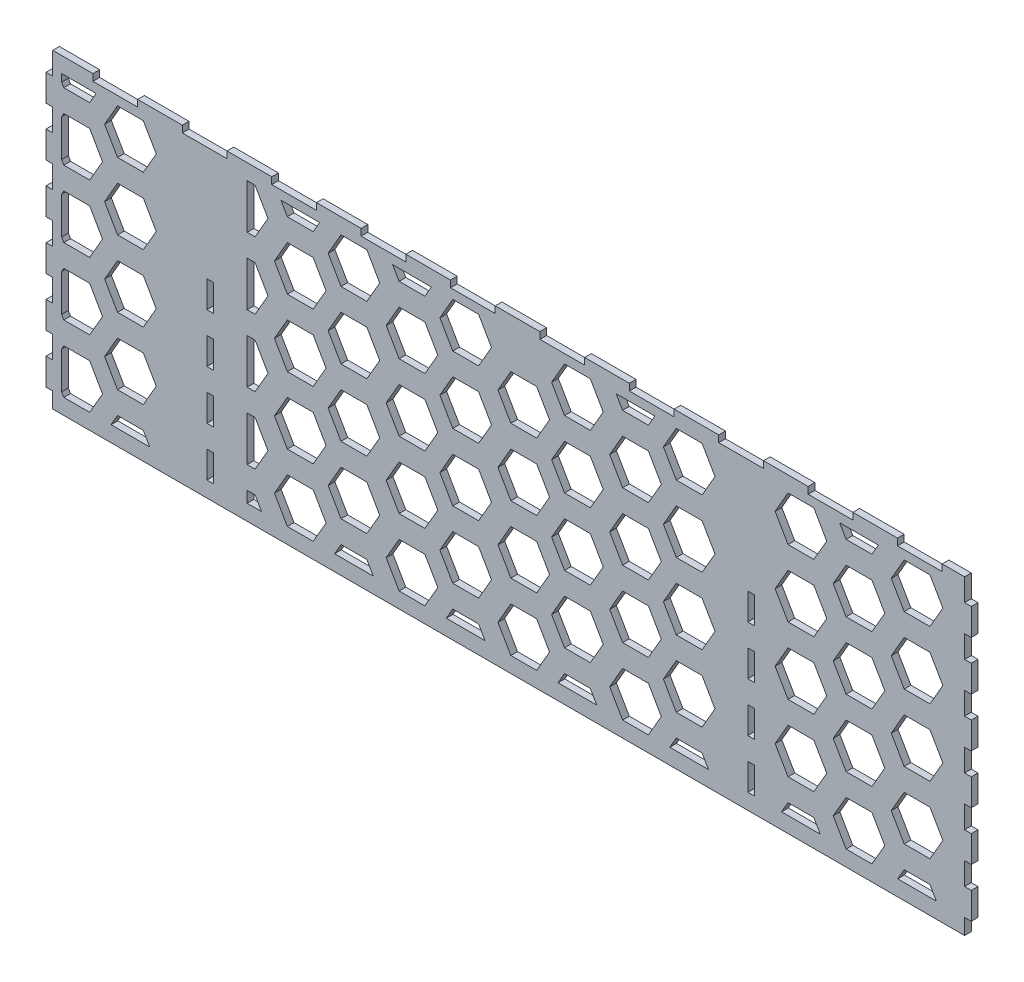
from build123d import *

# Parameters (mm, degrees)
SKETCH1_W           = 414
SKETCH1_H           = 139
SKETCH1_W_2         = 3
SKETCH1_H_2         = 12
BOSS_EXTRUDE1_DEPTH = 3
SKETCH3_W           = 20
SKETCH3_H           = 3
CUT_EXTRUDE2_DEPTH  = 3
SKETCH4_W           = 3
SKETCH4_H           = 12
CUT_EXTRUDE3_DEPTH  = 3


with BuildPart() as part:
    # Sketch1 → Boss-Extrude1 (new body)
    with BuildSketch(Plane.XY.offset(152)):
        Rectangle(SKETCH1_W, SKETCH1_H)
        with Locations((108.5, 9.5)):
            Rectangle(SKETCH1_W_2, SKETCH1_H_2, mode=Mode.SUBTRACT)
        with Locations((108.5, -12.5)):
            Rectangle(SKETCH1_W_2, SKETCH1_H_2, mode=Mode.SUBTRACT)
        with Locations((108.5, -56.5)):
            Rectangle(SKETCH1_W_2, SKETCH1_H_2, mode=Mode.SUBTRACT)
        with Locations((108.5, -34.5)):
            Rectangle(SKETCH1_W_2, SKETCH1_H_2, mode=Mode.SUBTRACT)
        with Locations((-133.5, -56.5)):
            Rectangle(SKETCH1_W_2, SKETCH1_H_2, mode=Mode.SUBTRACT)
        with Locations((-133.5, -34.5)):
            Rectangle(SKETCH1_W_2, SKETCH1_H_2, mode=Mode.SUBTRACT)
        with Locations((-133.5, -12.5)):
            Rectangle(SKETCH1_W_2, SKETCH1_H_2, mode=Mode.SUBTRACT)
        with Locations((-133.5, 9.5)):
            Rectangle(SKETCH1_W_2, SKETCH1_H_2, mode=Mode.SUBTRACT)
        Polygon((119.226497308, 52.5), (125, 42.5), (136.547005384, 42.5), (142.320508076, 52.5), (136.547005384, 62.5), (125, 62.5), align=None, mode=Mode.SUBTRACT)
        Polygon((171.188021535, 52.5), (176.961524227, 42.5), (188.508529611, 42.5), (194.282032303, 52.5), (188.508529611, 62.5), (176.961524227, 62.5), align=None, mode=Mode.SUBTRACT)
        Polygon((150.980762113, 47.5), (145.207259422, 37.5), (150.980762113, 27.5), (162.527767497, 27.5), (168.301270189, 37.5), (162.527767497, 47.5), align=None, mode=Mode.SUBTRACT)
        Polygon((171.188021535, 22.5), (176.961524227, 12.5), (188.508529611, 12.5), (194.282032303, 22.5), (188.508529611, 32.5), (176.961524227, 32.5), align=None, mode=Mode.SUBTRACT)
        Polygon((150.980762113, 17.5), (145.207259422, 7.5), (150.980762113, -2.5), (162.527767497, -2.5), (168.301270189, 7.5), (162.527767497, 17.5), align=None, mode=Mode.SUBTRACT)
        Polygon((119.226497308, 22.5), (125, 12.5), (136.547005384, 12.5), (142.320508076, 22.5), (136.547005384, 32.5), (125, 32.5), align=None, mode=Mode.SUBTRACT)
        Polygon((171.188021535, -7.5), (176.961524227, -17.5), (188.508529611, -17.5), (194.282032303, -7.5), (188.508529611, 2.5), (176.961524227, 2.5), align=None, mode=Mode.SUBTRACT)
        Polygon((150.980762113, -12.5), (145.207259422, -22.5), (150.980762113, -32.5), (162.527767497, -32.5), (168.301270189, -22.5), (162.527767497, -12.5), align=None, mode=Mode.SUBTRACT)
        Polygon((119.226497308, -7.5), (125, -17.5), (136.547005384, -17.5), (142.320508076, -7.5), (136.547005384, 2.5), (125, 2.5), align=None, mode=Mode.SUBTRACT)
        Polygon((171.188021535, -37.5), (176.961524227, -47.5), (188.508529611, -47.5), (194.282032303, -37.5), (188.508529611, -27.5), (176.961524227, -27.5), align=None, mode=Mode.SUBTRACT)
        Polygon((150.980762113, -42.5), (145.207259422, -52.5), (150.980762113, -62.5), (162.527767497, -62.5), (168.301270189, -52.5), (162.527767497, -42.5), align=None, mode=Mode.SUBTRACT)
        Polygon((119.226497308, -37.5), (125, -47.5), (136.547005384, -47.5), (142.320508076, -37.5), (136.547005384, -27.5), (125, -27.5), align=None, mode=Mode.SUBTRACT)
        Polygon((191.395280957, -62.5), (188.508529611, -57.5), (176.961524227, -57.5), (174.074772881, -62.5), align=None, mode=Mode.SUBTRACT)
        Polygon((139.43375673, -62.5), (136.547005384, -57.5), (125, -57.5), (122.113248654, -62.5), align=None, mode=Mode.SUBTRACT)
        Polygon((148.094010768, 62.5), (150.980762113, 57.5), (162.527767497, 57.5), (165.414518843, 62.5), align=None, mode=Mode.SUBTRACT)
        Polygon((89.43375673, -62.5), (86.547005384, -57.5), (75, -57.5), (72.113248654, -62.5), align=None, mode=Mode.SUBTRACT)
        Polygon((69.226497308, -37.5), (75, -47.5), (86.547005384, -47.5), (92.320508076, -37.5), (86.547005384, -27.5), (75, -27.5), align=None, mode=Mode.SUBTRACT)
        Polygon((69.226497308, -7.5), (75, -17.5), (86.547005384, -17.5), (92.320508076, -7.5), (86.547005384, 2.5), (75, 2.5), align=None, mode=Mode.SUBTRACT)
        Polygon((69.226497308, 22.5), (75, 12.5), (86.547005384, 12.5), (92.320508076, 22.5), (86.547005384, 32.5), (75, 32.5), align=None, mode=Mode.SUBTRACT)
        Polygon((69.226497308, 52.5), (75, 42.5), (86.547005384, 42.5), (92.320508076, 52.5), (86.547005384, 62.5), (75, 62.5), align=None, mode=Mode.SUBTRACT)
        Polygon((39.43375673, -62.5), (36.547005384, -57.5), (25, -57.5), (22.113248654, -62.5), align=None, mode=Mode.SUBTRACT)
        Polygon((50.980762114, -42.5), (45.207259422, -52.5), (50.980762114, -62.5), (62.527767497, -62.5), (68.301270189, -52.5), (62.527767497, -42.5), align=None, mode=Mode.SUBTRACT)
        Polygon((19.226497308, -37.5), (25, -47.5), (36.547005384, -47.5), (42.320508076, -37.5), (36.547005384, -27.5), (25, -27.5), align=None, mode=Mode.SUBTRACT)
        Polygon((50.980762114, -12.5), (45.207259422, -22.5), (50.980762114, -32.5), (62.527767497, -32.5), (68.301270189, -22.5), (62.527767497, -12.5), align=None, mode=Mode.SUBTRACT)
        Polygon((19.226497308, -7.5), (25, -17.5), (36.547005384, -17.5), (42.320508076, -7.5), (36.547005384, 2.5), (25, 2.5), align=None, mode=Mode.SUBTRACT)
        Polygon((50.980762114, 17.5), (45.207259422, 7.5), (50.980762114, -2.5), (62.527767497, -2.5), (68.301270189, 7.5), (62.527767497, 17.5), align=None, mode=Mode.SUBTRACT)
        Polygon((19.226497308, 22.5), (25, 12.5), (36.547005384, 12.5), (42.320508076, 22.5), (36.547005384, 32.5), (25, 32.5), align=None, mode=Mode.SUBTRACT)
        Polygon((50.980762114, 47.5), (45.207259422, 37.5), (50.980762114, 27.5), (62.527767497, 27.5), (68.301270189, 37.5), (62.527767497, 47.5), align=None, mode=Mode.SUBTRACT)
        Polygon((19.226497308, 52.5), (25, 42.5), (36.547005384, 42.5), (42.320508076, 52.5), (36.547005384, 62.5), (25, 62.5), align=None, mode=Mode.SUBTRACT)
        Polygon((48.094010768, 62.5), (50.980762114, 57.5), (62.527767497, 57.5), (65.414518843, 62.5), align=None, mode=Mode.SUBTRACT)
        Polygon((-10.56624327, -62.5), (-13.452994616, -57.5), (-25, -57.5), (-27.886751346, -62.5), align=None, mode=Mode.SUBTRACT)
        Polygon((0.980762114, -42.5), (-4.792740578, -52.5), (0.980762114, -62.5), (12.527767497, -62.5), (18.301270189, -52.5), (12.527767497, -42.5), align=None, mode=Mode.SUBTRACT)
        Polygon((-30.773502692, -37.5), (-25, -47.5), (-13.452994616, -47.5), (-7.679491924, -37.5), (-13.452994616, -27.5), (-25, -27.5), align=None, mode=Mode.SUBTRACT)
        Polygon((0.980762114, -12.5), (-4.792740578, -22.5), (0.980762114, -32.5), (12.527767497, -32.5), (18.301270189, -22.5), (12.527767497, -12.5), align=None, mode=Mode.SUBTRACT)
        Polygon((-30.773502692, -7.5), (-25, -17.5), (-13.452994616, -17.5), (-7.679491924, -7.5), (-13.452994616, 2.5), (-25, 2.5), align=None, mode=Mode.SUBTRACT)
        Polygon((0.980762114, 17.5), (-4.792740578, 7.5), (0.980762114, -2.5), (12.527767497, -2.5), (18.301270189, 7.5), (12.527767497, 17.5), align=None, mode=Mode.SUBTRACT)
        Polygon((-30.773502692, 22.5), (-25, 12.5), (-13.452994616, 12.5), (-7.679491924, 22.5), (-13.452994616, 32.5), (-25, 32.5), align=None, mode=Mode.SUBTRACT)
        Polygon((0.980762114, 47.5), (-4.792740578, 37.5), (0.980762114, 27.5), (12.527767497, 27.5), (18.301270189, 37.5), (12.527767497, 47.5), align=None, mode=Mode.SUBTRACT)
        Polygon((-30.773502692, 52.5), (-25, 42.5), (-13.452994616, 42.5), (-7.679491924, 52.5), (-13.452994616, 62.5), (-25, 62.5), align=None, mode=Mode.SUBTRACT)
        Polygon((-60.56624327, -62.5), (-63.452994616, -57.5), (-75, -57.5), (-77.886751346, -62.5), align=None, mode=Mode.SUBTRACT)
        Polygon((-49.019237886, -42.5), (-54.792740578, -52.5), (-49.019237886, -62.5), (-37.472232503, -62.5), (-31.698729811, -52.5), (-37.472232503, -42.5), align=None, mode=Mode.SUBTRACT)
        Polygon((-80.773502692, -37.5), (-75, -47.5), (-63.452994616, -47.5), (-57.679491924, -37.5), (-63.452994616, -27.5), (-75, -27.5), align=None, mode=Mode.SUBTRACT)
        Polygon((-49.019237886, -12.5), (-54.792740578, -22.5), (-49.019237886, -32.5), (-37.472232503, -32.5), (-31.698729811, -22.5), (-37.472232503, -12.5), align=None, mode=Mode.SUBTRACT)
        Polygon((-80.773502692, -7.5), (-75, -17.5), (-63.452994616, -17.5), (-57.679491924, -7.5), (-63.452994616, 2.5), (-75, 2.5), align=None, mode=Mode.SUBTRACT)
        Polygon((-49.019237886, 17.5), (-54.792740578, 7.5), (-49.019237886, -2.5), (-37.472232503, -2.5), (-31.698729811, 7.5), (-37.472232503, 17.5), align=None, mode=Mode.SUBTRACT)
        Polygon((-80.773502692, 22.5), (-75, 12.5), (-63.452994616, 12.5), (-57.679491924, 22.5), (-63.452994616, 32.5), (-75, 32.5), align=None, mode=Mode.SUBTRACT)
        Polygon((-49.019237886, 47.5), (-54.792740578, 37.5), (-49.019237886, 27.5), (-37.472232503, 27.5), (-31.698729811, 37.5), (-37.472232503, 47.5), align=None, mode=Mode.SUBTRACT)
        Polygon((-80.773502692, 52.5), (-75, 42.5), (-63.452994616, 42.5), (-57.679491924, 52.5), (-63.452994616, 62.5), (-75, 62.5), align=None, mode=Mode.SUBTRACT)
        Polygon((-51.905989232, 62.5), (-49.019237886, 57.5), (-37.472232503, 57.5), (-34.585481157, 62.5), align=None, mode=Mode.SUBTRACT)
        Polygon((-110.56624327, -62.5), (-113.452994616, -57.5), (-117, -57.5), (-117, -62.5), align=None, mode=Mode.SUBTRACT)
        Polygon((-99.019237886, -42.5), (-104.792740578, -52.5), (-99.019237886, -62.5), (-87.472232503, -62.5), (-81.698729811, -52.5), (-87.472232503, -42.5), align=None, mode=Mode.SUBTRACT)
        Polygon((-117, -47.5), (-113.452994616, -47.5), (-107.679491924, -37.5), (-113.452994616, -27.5), (-117, -27.5), align=None, mode=Mode.SUBTRACT)
        Polygon((-99.019237886, -12.5), (-104.792740578, -22.5), (-99.019237886, -32.5), (-87.472232503, -32.5), (-81.698729811, -22.5), (-87.472232503, -12.5), align=None, mode=Mode.SUBTRACT)
        Polygon((-117, -17.5), (-113.452994616, -17.5), (-107.679491924, -7.5), (-113.452994616, 2.5), (-117, 2.5), align=None, mode=Mode.SUBTRACT)
        Polygon((-99.019237886, 17.5), (-104.792740578, 7.5), (-99.019237886, -2.5), (-87.472232503, -2.5), (-81.698729811, 7.5), (-87.472232503, 17.5), align=None, mode=Mode.SUBTRACT)
        Polygon((-117, 12.5), (-113.452994616, 12.5), (-107.679491924, 22.5), (-113.452994616, 32.5), (-117, 32.5), align=None, mode=Mode.SUBTRACT)
        Polygon((-99.019237886, 47.5), (-104.792740578, 37.5), (-99.019237886, 27.5), (-87.472232503, 27.5), (-81.698729811, 37.5), (-87.472232503, 47.5), align=None, mode=Mode.SUBTRACT)
        Polygon((-117, 42.5), (-113.452994616, 42.5), (-107.679491924, 52.5), (-113.452994616, 62.5), (-117, 62.5), align=None, mode=Mode.SUBTRACT)
        Polygon((-101.905989232, 62.5), (-99.019237886, 57.5), (-87.472232503, 57.5), (-84.585481157, 62.5), align=None, mode=Mode.SUBTRACT)
        Polygon((-160.56624327, -62.5), (-163.452994616, -57.5), (-175, -57.5), (-177.886751346, -62.5), align=None, mode=Mode.SUBTRACT)
        Polygon((-180.773502692, -37.5), (-175, -47.5), (-163.452994616, -47.5), (-157.679491924, -37.5), (-163.452994616, -27.5), (-175, -27.5), align=None, mode=Mode.SUBTRACT)
        Polygon((-180.773502692, -7.5), (-175, -17.5), (-163.452994616, -17.5), (-157.679491924, -7.5), (-163.452994616, 2.5), (-175, 2.5), align=None, mode=Mode.SUBTRACT)
        Polygon((-180.773502692, 22.5), (-175, 12.5), (-163.452994616, 12.5), (-157.679491924, 22.5), (-163.452994616, 32.5), (-175, 32.5), align=None, mode=Mode.SUBTRACT)
        Polygon((-180.773502692, 52.5), (-175, 42.5), (-163.452994616, 42.5), (-157.679491924, 52.5), (-163.452994616, 62.5), (-175, 62.5), align=None, mode=Mode.SUBTRACT)
        Polygon((-199.019237886, -42.5), (-200, -44.198729811), (-200, -60.801270189), (-199.019237886, -62.5), (-187.472232503, -62.5), (-181.698729811, -52.5), (-187.472232503, -42.5), align=None, mode=Mode.SUBTRACT)
        Polygon((-199.019237886, -12.5), (-200, -14.198729811), (-200, -30.801270189), (-199.019237886, -32.5), (-187.472232503, -32.5), (-181.698729811, -22.5), (-187.472232503, -12.5), align=None, mode=Mode.SUBTRACT)
        Polygon((-199.019237886, 17.5), (-200, 15.801270189), (-200, -0.801270189), (-199.019237886, -2.5), (-187.472232503, -2.5), (-181.698729811, 7.5), (-187.472232503, 17.5), align=None, mode=Mode.SUBTRACT)
        Polygon((-199.019237886, 47.5), (-200, 45.801270189), (-200, 29.198729811), (-199.019237886, 27.5), (-187.472232503, 27.5), (-181.698729811, 37.5), (-187.472232503, 47.5), align=None, mode=Mode.SUBTRACT)
        Polygon((-200, 59.198729811), (-199.019237886, 57.5), (-187.472232503, 57.5), (-184.585481157, 62.5), (-200, 62.5), align=None, mode=Mode.SUBTRACT)
    extrude(amount=BOSS_EXTRUDE1_DEPTH)

    # Sketch3 → Cut-Extrude2 (cut)
    with BuildSketch(Plane(origin=(0, 0, 152), x_dir=(-1, 0, 0), z_dir=(0, 0, -1))):
        with Locations((-184, 68)):
            Rectangle(SKETCH3_W, SKETCH3_H)
        with Locations((-144, 68)):
            Rectangle(SKETCH3_W, SKETCH3_H)
        with Locations((-104, 68)):
            Rectangle(SKETCH3_W, SKETCH3_H)
        with Locations((-64, 68)):
            Rectangle(SKETCH3_W, SKETCH3_H)
        with Locations((-24, 68)):
            Rectangle(SKETCH3_W, SKETCH3_H)
        with Locations((16, 68)):
            Rectangle(SKETCH3_W, SKETCH3_H)
        with Locations((56, 68)):
            Rectangle(SKETCH3_W, SKETCH3_H)
        with Locations((96, 68)):
            Rectangle(SKETCH3_W, SKETCH3_H)
        with Locations((136, 68)):
            Rectangle(SKETCH3_W, SKETCH3_H)
        with Locations((176, 68)):
            Rectangle(SKETCH3_W, SKETCH3_H)
    extrude(amount=-CUT_EXTRUDE2_DEPTH, mode=Mode.SUBTRACT)

    # Sketch4 → Cut-Extrude3 (cut)
    with BuildSketch(Plane.ZY.offset(207)):
        with BuildLine():
            Line((152, 44), (145.4, 44))
            Line((145.4, 44), (145.4, 47))
            Line((145.4, 47), (140.4, 47))
            Line((140.4, 47), (140.4, 44))
            Line((140.4, 44), (135.4, 44))
            Line((135.4, 44), (135.4, 43.377104502))
            ThreePointArc((135.4, 43.377104502), (139.572199023, -13.668492876), (152, -69.5))
            Line((152, -69.5), (316, -69.5))
            ThreePointArc((316, -69.5), (328.427800977, -13.668492876), (332.6, 43.377104502))
            Line((332.6, 43.377104502), (332.6, 44))
            Line((332.6, 44), (327.6, 44))
            Line((327.6, 44), (327.6, 47))
            Line((327.6, 47), (322.6, 47))
            Line((322.6, 47), (322.6, 44))
            Line((322.6, 44), (316, 44))
            Line((316, 44), (316, 47.5))
            Line((316, 47.5), (313, 47.5))
            Line((313, 47.5), (313, 59.5))
            Line((313, 59.5), (316, 59.5))
            Line((316, 59.5), (316, 69.5))
            Line((316, 69.5), (305, 69.5))
            Line((305, 69.5), (305, 66.5))
            Line((305, 66.5), (295, 66.5))
            Line((295, 66.5), (295, 69.5))
            Line((295, 69.5), (283, 69.5))
            Line((283, 69.5), (283, 66.5))
            Line((283, 66.5), (273, 66.5))
            Line((273, 66.5), (273, 69.5))
            Line((273, 69.5), (261, 69.5))
            Line((261, 69.5), (261, 66.5))
            Line((261, 66.5), (251, 66.5))
            Line((251, 66.5), (251, 69.5))
            Line((251, 69.5), (239, 69.5))
            Line((239, 69.5), (239, 66.5))
            Line((239, 66.5), (229, 66.5))
            Line((229, 66.5), (229, 69.5))
            Line((229, 69.5), (217, 69.5))
            Line((217, 69.5), (217, 66.5))
            Line((217, 66.5), (207, 66.5))
            Line((207, 66.5), (207, 69.5))
            Line((207, 69.5), (195, 69.5))
            Line((195, 69.5), (195, 66.5))
            Line((195, 66.5), (185, 66.5))
            Line((185, 66.5), (185, 69.5))
            Line((185, 69.5), (173, 69.5))
            Line((173, 69.5), (173, 66.5))
            Line((173, 66.5), (163, 66.5))
            Line((163, 66.5), (163, 69.5))
            Line((163, 69.5), (152, 69.5))
            Line((152, 69.5), (152, 59.5))
            Line((152, 59.5), (155, 59.5))
            Line((155, 59.5), (155, 47.5))
            Line((155, 47.5), (152, 47.5))
            Line((152, 47.5), (152, 44))
        make_face()
        with Locations((153.5, 31.5)):
            Rectangle(SKETCH4_W, SKETCH4_H, mode=Mode.SUBTRACT)
        with Locations((314.5, 31.5)):
            Rectangle(SKETCH4_W, SKETCH4_H, mode=Mode.SUBTRACT)
        with Locations((153.5, -56.5)):
            Rectangle(SKETCH4_W, SKETCH4_H, mode=Mode.SUBTRACT)
        with Locations((314.5, 9.5)):
            Rectangle(SKETCH4_W, SKETCH4_H, mode=Mode.SUBTRACT)
        with Locations((314.5, -12.5)):
            Rectangle(SKETCH4_W, SKETCH4_H, mode=Mode.SUBTRACT)
        with Locations((314.5, -34.5)):
            Rectangle(SKETCH4_W, SKETCH4_H, mode=Mode.SUBTRACT)
        with Locations((314.5, -56.5)):
            Rectangle(SKETCH4_W, SKETCH4_H, mode=Mode.SUBTRACT)
        with Locations((153.5, 9.5)):
            Rectangle(SKETCH4_W, SKETCH4_H, mode=Mode.SUBTRACT)
        with Locations((153.5, -12.5)):
            Rectangle(SKETCH4_W, SKETCH4_H, mode=Mode.SUBTRACT)
        with Locations((153.5, -34.5)):
            Rectangle(SKETCH4_W, SKETCH4_H, mode=Mode.SUBTRACT)
    cut_extrude3 = extrude(amount=-CUT_EXTRUDE3_DEPTH, mode=Mode.SUBTRACT)

    # Mirror1: Cut-Extrude3 across plane
    add(cut_extrude3.mirror(Plane(origin=(0, 0, 0), x_dir=(0, 0, 1), z_dir=(1, 0, 0))), mode=Mode.SUBTRACT)


solid = part.part
